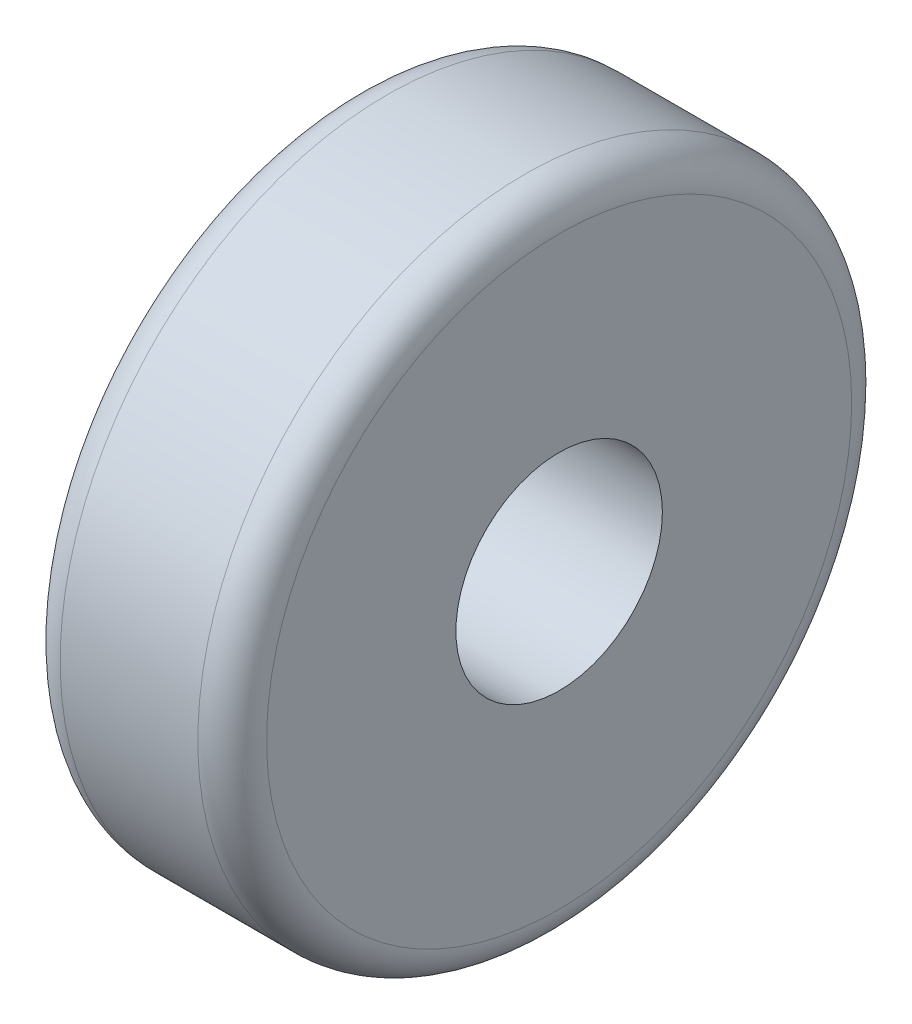
from build123d import *

# Parameters (mm, degrees)
SKETCH_1_R      = 9.5
SKETCH_1_R_2    = 3
EXTRUDE_1_DEPTH = 6
FILLET_1_R      = 1


with BuildPart() as part:
    # 草图1 → 凸台-拉伸1 (new body)
    with BuildSketch(Plane(origin=(0, 0, 0), x_dir=(0, 0, -1), z_dir=(1, 0, 0))):
        Circle(SKETCH_1_R)
        Circle(SKETCH_1_R_2, mode=Mode.SUBTRACT)
    extrude(amount=EXTRUDE_1_DEPTH)

    # 圆角1
    fillet_1_edges = [part.edges().sort_by_distance(p)[0] for p in [
        (0, 0, 9.5),
        (6, 0, 9.5),
    ]]
    fillet(fillet_1_edges, radius=FILLET_1_R)


solid = part.part
